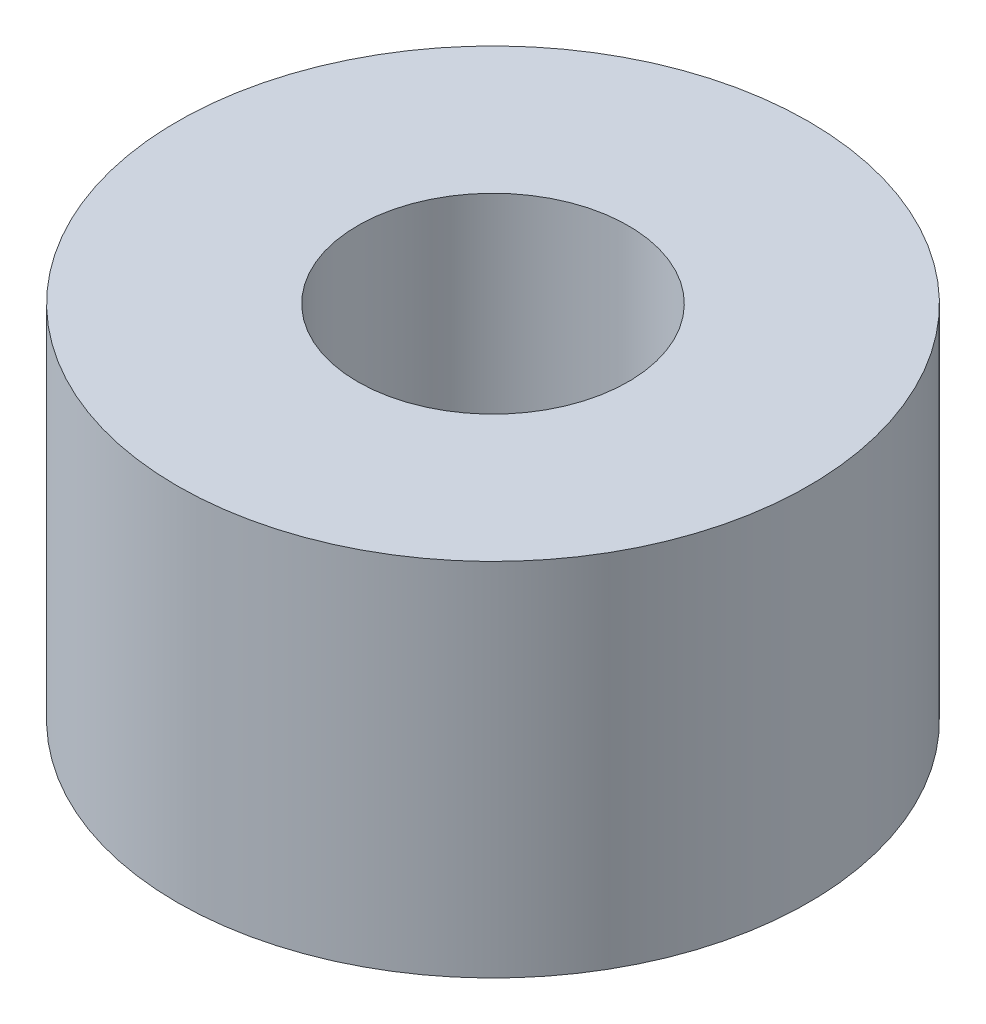
from build123d import *

# Parameters (mm, degrees)
SKETCH_1_R      = 3.5
SKETCH_1_R_2    = 1.5
EXTRUDE_1_DEPTH = 4


with BuildPart() as part:
    # 草图1 → 凸台-拉伸1 (new body)
    with BuildSketch(Plane(origin=(0, 0, 0), x_dir=(1, 0, 0), z_dir=(0, 1, 0))):
        Circle(SKETCH_1_R)
        Circle(SKETCH_1_R_2, mode=Mode.SUBTRACT)
    extrude(amount=EXTRUDE_1_DEPTH)


solid = part.part
